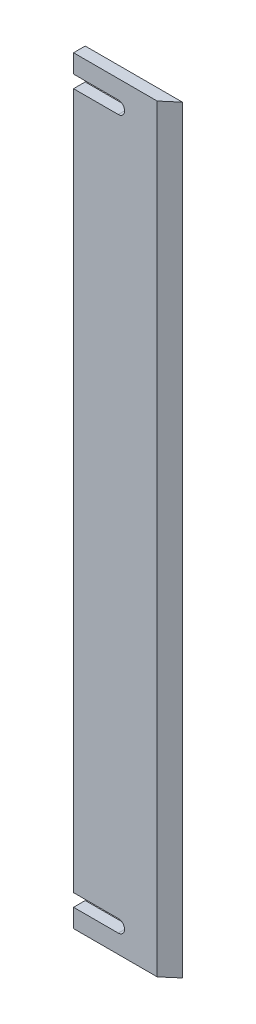
from build123d import *

# Parameters (mm, degrees)
BOSS_EXTRUDE1_DEPTH   = 195
CORTAR_EXTRUIR4_DEPTH = 10


with BuildPart() as part:
    # Sketch1 → Boss-Extrude1 (new body)
    with BuildSketch(Plane(origin=(0, 0, 0), x_dir=(1, 0, 0), z_dir=(0, 1, 0))):
        Polygon((-12.850649351, 0), (8.649350649, 0), (12.149350649, 3), (-12.850649351, 3), align=None)
    extrude(amount=BOSS_EXTRUDE1_DEPTH)

    # Croquis1 → Cortar-Extruir4 (cut)
    with BuildSketch(Plane.XY):
        with BuildLine():
            Line((-1.350649351, 4.75), (-12.850649351, 4.75))
            Line((-12.850649351, 4.75), (-12.850649351, 8))
            Line((-12.850649351, 8), (-1.350649351, 8))
            ThreePointArc((-1.350649351, 8), (0.274350649, 6.375), (-1.350649351, 4.75))
        make_face()
        with BuildLine():
            Line((-12.850649351, 187), (-1.350649351, 187))
            ThreePointArc((-1.350649351, 187), (0.274350649, 188.625), (-1.350649351, 190.25))
            Line((-1.350649351, 190.25), (-12.850649351, 190.25))
            Line((-12.850649351, 190.25), (-12.850649351, 187))
        make_face()
    extrude(amount=-CORTAR_EXTRUIR4_DEPTH, mode=Mode.SUBTRACT)


solid = part.part
